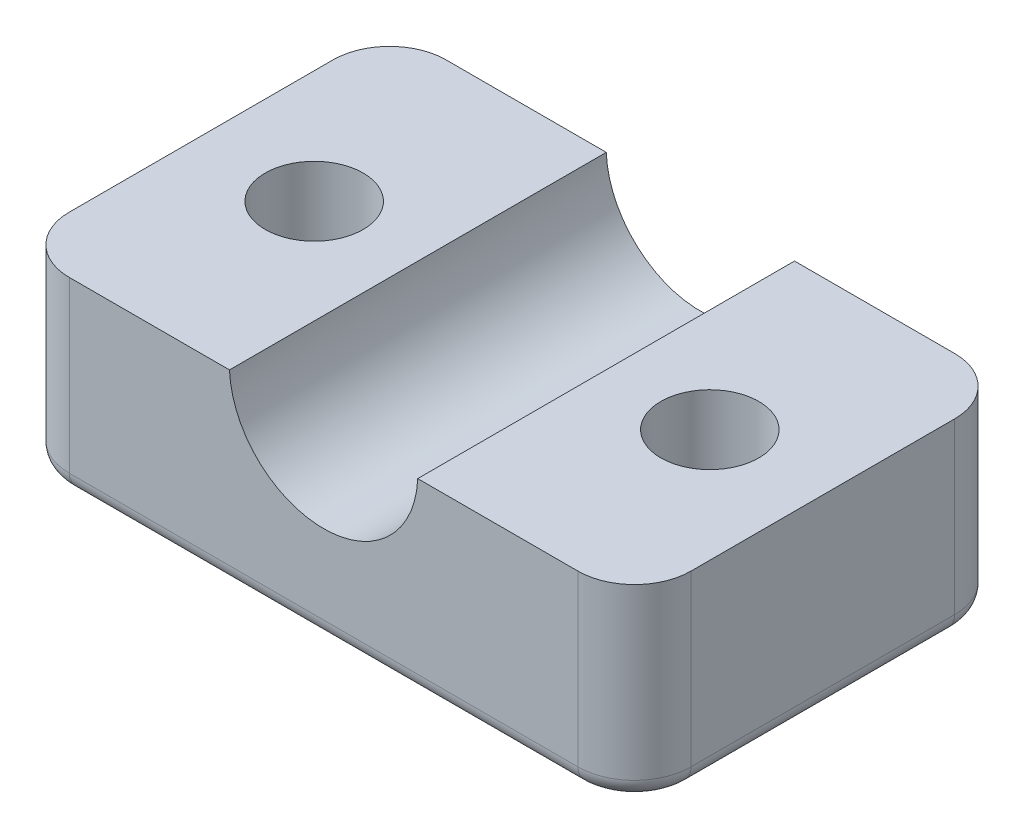
from build123d import *

# Parameters (mm, degrees)
SKETCH1_R           = 2.6
BOSS_EXTRUDE3_DEPTH = 10
SKETCH5_R           = 5
CUT_EXTRUDE3_DEPTH  = 20
FILLET2_R           = 1


with BuildPart() as part:
    # Sketch1 → Boss-Extrude3 (new body)
    with BuildSketch(Plane(origin=(0, 0, 0), x_dir=(1, 0, 0), z_dir=(0, 1, 0))):
        with BuildLine():
            Line((-13.5, -10), (13.5, -10))
            ThreePointArc((13.5, -10), (15.621320344, -9.121320344), (16.5, -7))
            Line((16.5, -7), (16.5, 7))
            ThreePointArc((16.5, 7), (15.621320344, 9.121320344), (13.5, 10))
            Line((13.5, 10), (-13.5, 10))
            ThreePointArc((-13.5, 10), (-15.621320344, 9.121320344), (-16.5, 7))
            Line((-16.5, 7), (-16.5, -7))
            ThreePointArc((-16.5, -7), (-15.621320344, -9.121320344), (-13.5, -10))
        make_face()
        with Locations((10.5, 0)):
            Circle(SKETCH1_R, mode=Mode.SUBTRACT)
        with Locations((-10.5, 0)):
            Circle(SKETCH1_R, mode=Mode.SUBTRACT)
    extrude(amount=BOSS_EXTRUDE3_DEPTH)

    # Sketch5 → Cut-Extrude3 (cut)
    with BuildSketch(Plane(origin=(0, 0, -10), x_dir=(-1, 0, 0), z_dir=(0, 0, -1))):
        with Locations((0, 10.2)):
            Circle(SKETCH5_R)
    extrude(amount=-CUT_EXTRUDE3_DEPTH, mode=Mode.SUBTRACT)

    # Fillet2
    fillet2_edges = [part.edges().sort_by_distance(p)[0] for p in [
        (0, 0, 10),
        (-15.621320344, 0, 9.121320344),
        (-16.5, 0, 0),
        (-15.621320344, 0, -9.121320344),
        (0, 0, -10),
        (15.621320344, 0, -9.121320344),
        (16.5, 0, 0),
        (15.621320344, 0, 9.121320344),
    ]]
    fillet(fillet2_edges, radius=FILLET2_R)


solid = part.part
